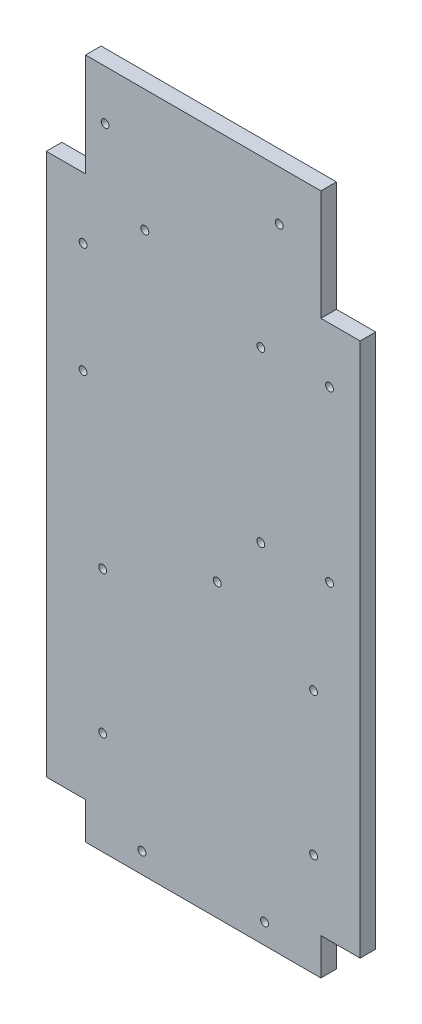
from build123d import *

# Parameters (mm, degrees)
SKETCH1_W           = 128
SKETCH1_H           = 278
BOSS_EXTRUDE1_DEPTH = 6.35
SKETCH2_W           = 16
SKETCH2_H           = 42
SKETCH2_H_2         = 45
SKETCH2_H_3         = 15
CUT_EXTRUDE1_DEPTH  = 31.7625
SKETCH5_R           = 1.6
CUT_EXTRUDE3_DEPTH  = 10


with BuildPart() as part:
    # Sketch1 → Boss-Extrude1 (new body)
    with BuildSketch(Plane.XY):
        with Locations((64, 139)):
            Rectangle(SKETCH1_W, SKETCH1_H)
    extrude(amount=BOSS_EXTRUDE1_DEPTH)

    # Sketch2 → Cut-Extrude1 (cut)
    with BuildSketch(Plane.XY.offset(6.35)):
        with Locations((8, 257)):
            Rectangle(SKETCH2_W, SKETCH2_H)
        with Locations((120, 255.5)):
            Rectangle(SKETCH2_W, SKETCH2_H_2)
        with Locations((120, 7.5)):
            Rectangle(SKETCH2_W, SKETCH2_H_3)
        with Locations((8, 7.5)):
            Rectangle(SKETCH2_W, SKETCH2_H_3)
    extrude(amount=-CUT_EXTRUDE1_DEPTH, mode=Mode.SUBTRACT)

    # Sketch5 → Cut-Extrude3 (cut)
    with BuildSketch(Plane.XY.offset(6.35)):
        with Locations((24, 257.75)):
            Circle(SKETCH5_R)
        with Locations((95, 257.75)):
            Circle(SKETCH5_R)
        with Locations((87.5, 210.5)):
            Circle(SKETCH5_R)
        with Locations((115.5, 210.5)):
            Circle(SKETCH5_R)
        with Locations((87.5, 141.5)):
            Circle(SKETCH5_R)
        with Locations((115.5, 141.5)):
            Circle(SKETCH5_R)
        with Locations((69.697400928, 118.75)):
            Circle(SKETCH5_R)
        with Locations((40.197400928, 228.25)):
            Circle(SKETCH5_R)
        with Locations((15, 211)):
            Circle(SKETCH5_R)
        with Locations((15, 166)):
            Circle(SKETCH5_R)
        with Locations((39, 8.308927031)):
            Circle(SKETCH5_R)
        with Locations((89, 8.308927031)):
            Circle(SKETCH5_R)
        with Locations((23, 100)):
            Circle(SKETCH5_R)
        with Locations((23, 42)):
            Circle(SKETCH5_R)
        with Locations((109, 42)):
            Circle(SKETCH5_R)
        with Locations((109, 100)):
            Circle(SKETCH5_R)
    extrude(amount=-CUT_EXTRUDE3_DEPTH, mode=Mode.SUBTRACT)


solid = part.part
